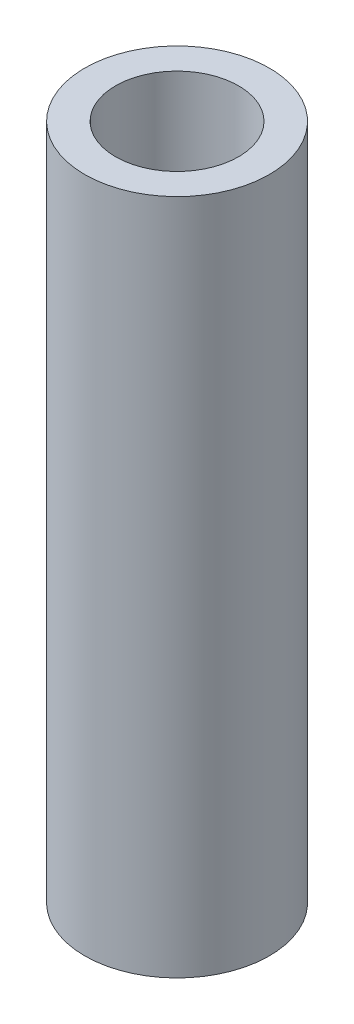
from build123d import *

# Parameters (mm, degrees)
SKETCH_1_R      = 3
SKETCH_1_R_2    = 2
EXTRUDE_1_DEPTH = 22


with BuildPart() as part:
    # Эскиз1 → Бобышка-Вытянуть1 (new body)
    with BuildSketch(Plane(origin=(0, 0, 0), x_dir=(1, 0, 0), z_dir=(0, 1, 0))):
        Circle(SKETCH_1_R)
        Circle(SKETCH_1_R_2, mode=Mode.SUBTRACT)
    extrude(amount=EXTRUDE_1_DEPTH)


solid = part.part
